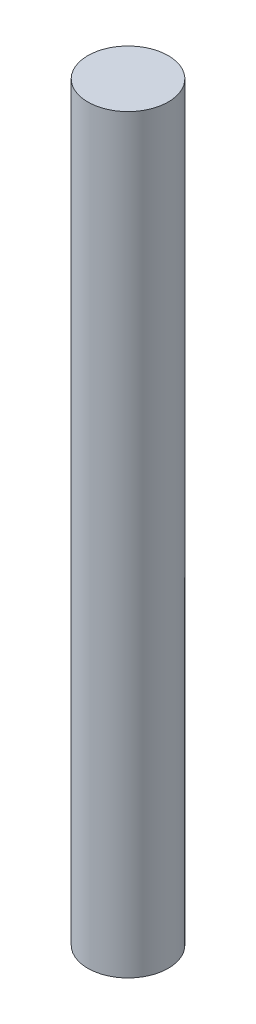
from build123d import *

# Parameters (mm, degrees)
SKETCH1_W = 7.5
SKETCH1_H = 140


with BuildPart() as part:
    # Sketch1 → Revolve1 (revolve)
    with BuildSketch(Plane(origin=(0, 0, 0), x_dir=(0, 0, -1), z_dir=(1, 0, 0))):
        with Locations((3.75, 70)):
            Rectangle(SKETCH1_W, SKETCH1_H)
    revolve(axis=Axis((0, 0, 0), (0, 1, 0)))


solid = part.part
